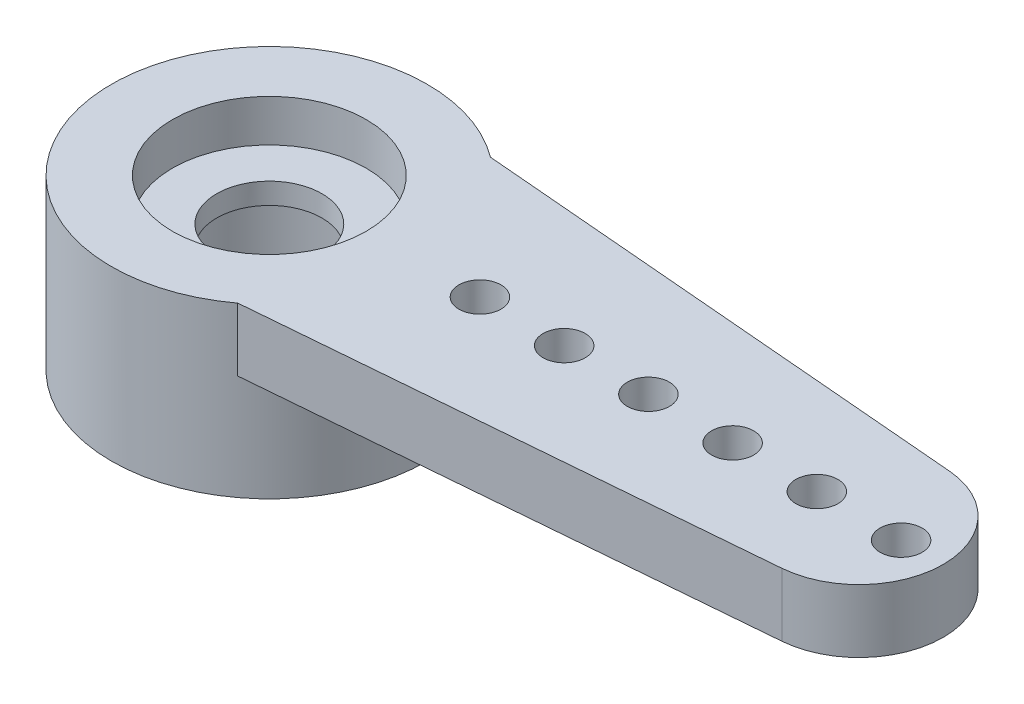
from build123d import *

# Parameters (mm, degrees)
SKETCH1_R           = 3.75
BOSS_EXTRUDE1_DEPTH = 4
SKETCH2_R           = 2.3
CUT_EXTRUDE1_DEPTH  = 1
SKETCH3_R           = 0.5
BOSS_EXTRUDE2_DEPTH = 1.5
SKETCH4_R           = 1.25
CUT_EXTRUDE2_DEPTH  = 4.5
SKETCH5_R           = 2.3
CUT_EXTRUDE3_DEPTH  = 2.5


with BuildPart() as part:
    # Sketch1 → Boss-Extrude1 (new body)
    with BuildSketch(Plane(origin=(0, 0, 0), x_dir=(1, 0, 0), z_dir=(0, 1, 0))):
        Circle(SKETCH1_R)
    extrude(amount=BOSS_EXTRUDE1_DEPTH)

    # Sketch2 → Cut-Extrude1 (cut)
    with BuildSketch(Plane(origin=(0, 4, 0), x_dir=(1, 0, 0), z_dir=(0, 1, 0))):
        Circle(SKETCH2_R)
    extrude(amount=-CUT_EXTRUDE1_DEPTH, mode=Mode.SUBTRACT)

    # Sketch3 → Boss-Extrude2 (add)
    with BuildSketch(Plane(origin=(0, 4, 0), x_dir=(1, 0, 0), z_dir=(0, 1, 0))):
        with BuildLine():
            Line((14.168399438, -1.992897797), (2.25, -3))
            ThreePointArc((2.25, -3), (3.75, 0), (2.25, 3))
            Line((2.25, 3), (14.168399438, 1.992897797))
            ThreePointArc((14.168399438, 1.992897797), (16, 0), (14.168399438, -1.992897797))
        make_face()
        with Locations((15, 0)):
            Circle(SKETCH3_R, mode=Mode.SUBTRACT)
        with Locations((5, 0)):
            Circle(SKETCH3_R, mode=Mode.SUBTRACT)
        with Locations((7, 0)):
            Circle(SKETCH3_R, mode=Mode.SUBTRACT)
        with Locations((9, 0)):
            Circle(SKETCH3_R, mode=Mode.SUBTRACT)
        with Locations((11, 0)):
            Circle(SKETCH3_R, mode=Mode.SUBTRACT)
        with Locations((13, 0)):
            Circle(SKETCH3_R, mode=Mode.SUBTRACT)
    extrude(amount=-BOSS_EXTRUDE2_DEPTH)

    # Sketch4 → Cut-Extrude2 (cut)
    with BuildSketch(Plane(origin=(0, 3, 0), x_dir=(1, 0, 0), z_dir=(0, 1, 0))):
        Circle(SKETCH4_R)
    extrude(amount=-CUT_EXTRUDE2_DEPTH, mode=Mode.SUBTRACT)

    # Sketch5 → Cut-Extrude3 (cut)
    with BuildSketch(Plane.XZ):
        Circle(SKETCH5_R)
    extrude(amount=-CUT_EXTRUDE3_DEPTH, mode=Mode.SUBTRACT)


solid = part.part
